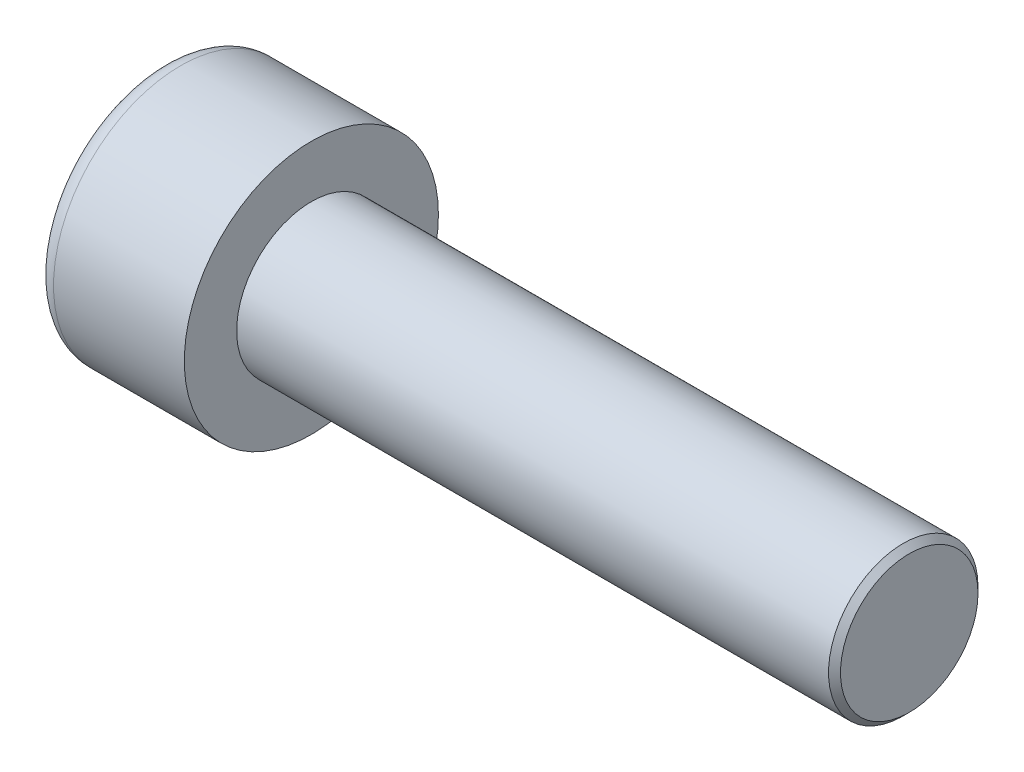
from build123d import *

# Parameters (mm, degrees)
SKETCH1_R           = 4.25
BASEHEAD_DEPTH      = 5
SKETCH2_R           = 2.5
BASEBODY_DEPTH      = 20
HEXAGONSOCKET_DEPTH = 2.5
TOPFILLET_R         = 0.625
CHAMFER1_SIZE       = 0.2


with BuildPart() as part:
    # Sketch1 → BaseHead (new body)
    with BuildSketch(Plane(origin=(0, 0, 0), x_dir=(0, 0, -1), z_dir=(1, 0, 0))):
        Circle(SKETCH1_R)
    extrude(amount=BASEHEAD_DEPTH)

    # Sketch2 → BaseBody (add)
    with BuildSketch(Plane(origin=(5, 0, 0), x_dir=(0, 0, -1), z_dir=(1, 0, 0))):
        Circle(SKETCH2_R)
    extrude(amount=BASEBODY_DEPTH)

    # Sketch3 → HexagonSocket (cut)
    with BuildSketch(Plane(origin=(0, 0, 0), x_dir=(0, 0, -1), z_dir=(1, 0, 0))):
        Polygon((2.309401077, 0), (1.154700538, 2), (-1.154700538, 2), (-2.309401077, 0), (-1.154700538, -2), (1.154700538, -2), align=None)
    extrude(amount=HEXAGONSOCKET_DEPTH, mode=Mode.SUBTRACT)

    # Sketch4 → Cut-Revolve1 (revolve, cut)
    with BuildSketch(Plane(origin=(-4.19613823, 0.75, 0), x_dir=(-1, 0, 0), z_dir=(0, 0, 1))):
        Polygon((-6.69613823, 2.75), (-7.850838768, 0.75), (-6.69613823, 0.75), align=None)
    revolve(axis=Axis((0.838992387, 0, 0), (-1, 0, 0)), mode=Mode.SUBTRACT)

    # TopFillet
    topfillet_edges = [part.edges().sort_by_distance(p)[0] for p in [
        (0, 0, 4.25),
    ]]
    fillet(topfillet_edges, radius=TOPFILLET_R)

    # Chamfer1
    chamfer1_edges = [part.edges().sort_by_distance(p)[0] for p in [
        (25, 0, 2.5),
    ]]
    chamfer(chamfer1_edges, length=CHAMFER1_SIZE)


solid = part.part
